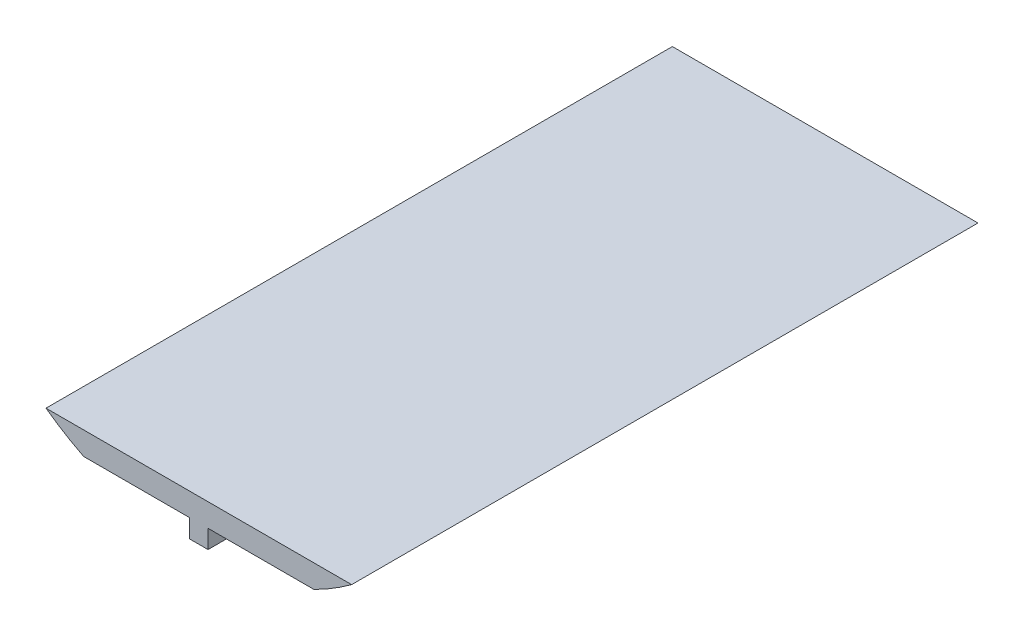
from build123d import *

# Parameters (mm, degrees)
SKETCH3_R           = 71.12
BOSS_EXTRUDE2_DEPTH = 172.72
CUT_EXTRUDE3_DEPTH  = 173.72
CUT_EXTRUDE4_DEPTH  = 173.72
SKETCH7_W           = 132.752189526
SKETCH7_H           = 172.72
CUT_EXTRUDE5_DEPTH  = 31.75
SKETCH8_W           = 5.08
SKETCH8_H           = 172.72
BOSS_EXTRUDE3_DEPTH = 5.08


with BuildPart() as part:
    # Sketch3 → Boss-Extrude2 (new body)
    with BuildSketch(Plane.XY):
        Circle(SKETCH3_R)
    extrude(amount=BOSS_EXTRUDE2_DEPTH)

    # Sketch4 → Cut-Extrude3 (cut, through all)
    with BuildSketch(Plane.XY.offset(172.72)):
        with BuildLine():
            Line((-31.75, -63.639546667), (31.75, -63.639546667))
            ThreePointArc((31.75, -63.639546667), (0, -71.12), (-31.75, -63.639546667))
        make_face()
    extrude(amount=-CUT_EXTRUDE3_DEPTH, mode=Mode.SUBTRACT)

    # Sketch5 → Cut-Extrude4 (cut, through all)
    with BuildSketch(Plane.XY.offset(172.72)):
        with BuildLine():
            Line((-66.376094763, -25.539546667), (66.376094763, -25.539546667))
            ThreePointArc((66.376094763, -25.539546667), (0, 71.12), (-66.376094763, -25.539546667))
        make_face()
    extrude(amount=-CUT_EXTRUDE4_DEPTH, mode=Mode.SUBTRACT)

    # Sketch7 → Cut-Extrude5 (cut)
    with BuildSketch(Plane(origin=(0, -25.539546667, 0), x_dir=(1, 0, 0), z_dir=(0, 1, 0))):
        with Locations((0, -86.36)):
            Rectangle(SKETCH7_W, SKETCH7_H)
    extrude(amount=-CUT_EXTRUDE5_DEPTH, mode=Mode.SUBTRACT)

    # Sketch8 → Boss-Extrude3 (add)
    with BuildSketch(Plane.XZ.offset(63.639546667)):
        with Locations((0, 86.36)):
            Rectangle(SKETCH8_W, SKETCH8_H)
    extrude(amount=BOSS_EXTRUDE3_DEPTH)


solid = part.part
